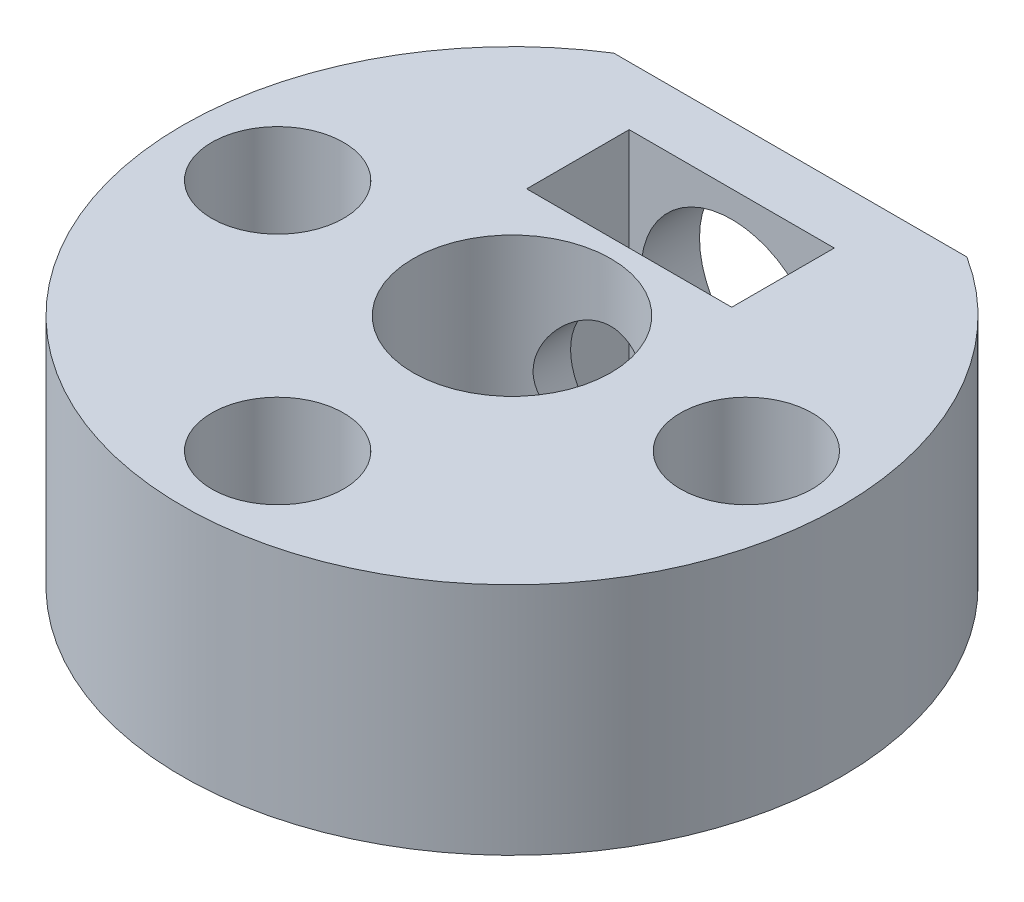
from build123d import *

# Parameters (mm, degrees)
BOSS_EXTRU_1_DEPTH                              = 8
SKETCH1_R                                       = 3.375
CUT_EXTRUDE1_DEPTH                              = 9
ESQUISSE7_W                                     = 7
ESQUISSE7_H                                     = 3.5
ENL_V_MAT_EXTRU_2_DEPTH                         = 9
CHAMBRAGE_POUR_VIS_T_TE_CYLINDRIQUE_D           = 2.5
CHAMBRAGE_POUR_VIS_T_TE_CYLINDRIQUE_CBORE_D     = 4.5
CHAMBRAGE_POUR_VIS_T_TE_CYLINDRIQUE_CBORE_DEPTH = 5.3
CBORE_FOR_M5_HEX_HEAD_BOLT1_D                   = 4
CBORE_FOR_M5_HEX_HEAD_BOLT1_DEPTH               = 9.499
CBORE_FOR_M5_HEX_HEAD_BOLT1_CBORE_D             = 6.2
CBORE_FOR_M5_HEX_HEAD_BOLT1_CBORE_DEPTH         = 2
CBORE_FOR_M5_HEX_HEAD_BOLT1_TIP                 = 1.201721238


with BuildPart() as part:
    # Esquisse1 → Boss.-Extru.1 (new body)
    with BuildSketch(Plane(origin=(0, 0, 0), x_dir=(1, 0, 0), z_dir=(0, 1, 0))):
        with BuildLine():
            Line((6.025985397, 9.5), (-6.025985397, 9.5))
            ThreePointArc((-6.025985397, 9.5), (0, -11.25), (6.025985397, 9.5))
        make_face()
    extrude(amount=BOSS_EXTRU_1_DEPTH)

    # Sketch1 → Cut-Extrude1 (cut, through all)
    with BuildSketch(Plane(origin=(0, 8, 0), x_dir=(1, 0, 0), z_dir=(0, 1, 0))):
        Circle(SKETCH1_R)
    extrude(amount=-CUT_EXTRUDE1_DEPTH, mode=Mode.SUBTRACT)

    # Esquisse7 → Enlèv. mat.-Extru.2 (cut, through all)
    with BuildSketch(Plane(origin=(0, 8, 0), x_dir=(1, 0, 0), z_dir=(0, 1, 0))):
        with Locations((0, 5.75)):
            Rectangle(ESQUISSE7_W, ESQUISSE7_H)
    extrude(amount=-ENL_V_MAT_EXTRU_2_DEPTH, mode=Mode.SUBTRACT)

    # Chambrage pour vis à tête cylindrique à 6 pans creux (ou vis CHC) M21 (through all)
    with Locations(Plane(origin=(0, 8, 0), x_dir=(1, 0, 0), z_dir=(0, 1, 0))):
        with Locations((-8, 0), (0, -8), (8, 0)):
            CounterBoreHole(CHAMBRAGE_POUR_VIS_T_TE_CYLINDRIQUE_D / 2, CHAMBRAGE_POUR_VIS_T_TE_CYLINDRIQUE_CBORE_D / 2, CHAMBRAGE_POUR_VIS_T_TE_CYLINDRIQUE_CBORE_DEPTH)

    # CBORE for M5 Hex Head Bolt1
    with Locations(Plane(origin=(0, 0, -9.5), x_dir=(-1, 0, 0), z_dir=(0, 0, -1))):
        with Locations((0, 4)):
            CounterBoreHole(CBORE_FOR_M5_HEX_HEAD_BOLT1_D / 2, CBORE_FOR_M5_HEX_HEAD_BOLT1_CBORE_D / 2, CBORE_FOR_M5_HEX_HEAD_BOLT1_CBORE_DEPTH, depth=CBORE_FOR_M5_HEX_HEAD_BOLT1_DEPTH)
            with Locations((0, 0, -(CBORE_FOR_M5_HEX_HEAD_BOLT1_DEPTH + CBORE_FOR_M5_HEX_HEAD_BOLT1_TIP / 2))):  # 118° drill point
                Cone(0, CBORE_FOR_M5_HEX_HEAD_BOLT1_D / 2, CBORE_FOR_M5_HEX_HEAD_BOLT1_TIP, mode=Mode.SUBTRACT)


solid = part.part
